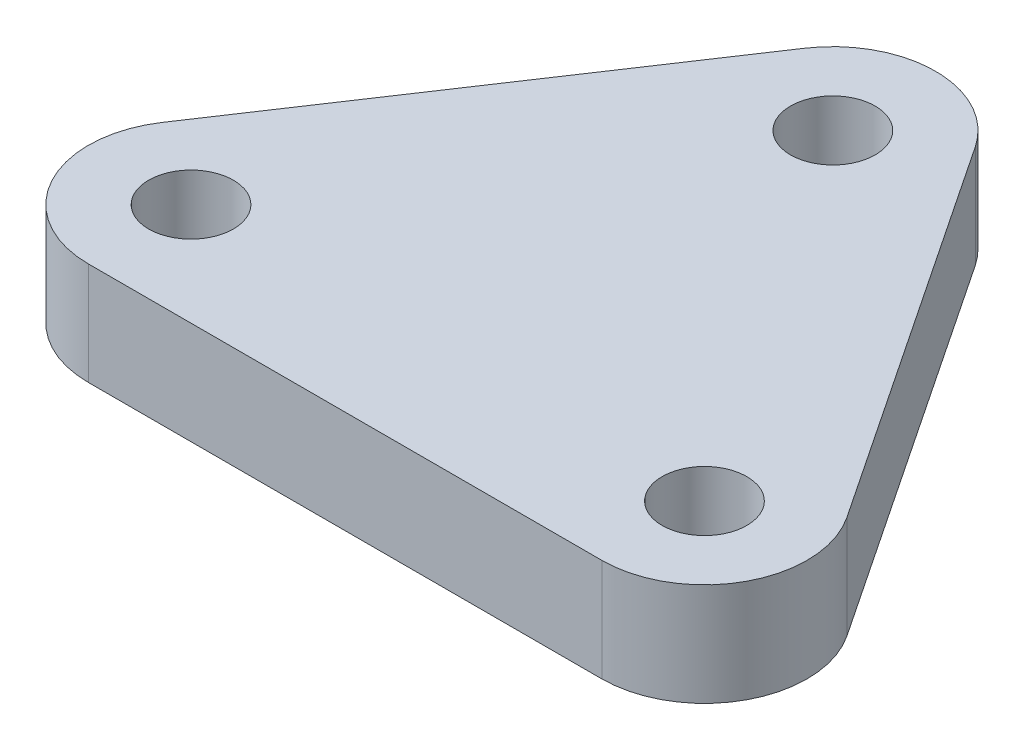
from build123d import *

# Parameters (mm, degrees)
EXTRUDE_1_DEPTH    = 4
HOLE_WIZARD_M4_1_D = 3.3


with BuildPart() as part:
    # 草图1 → 凸台-拉伸1 (new body)
    with BuildSketch(Plane(origin=(0, 0, 0), x_dir=(1, 0, 0), z_dir=(0, 1, 0))):
        with BuildLine():
            Line((-3.328201177, 17.218800785), (-13.328201177, 2.218800785))
            ThreePointArc((-13.328201177, 2.218800785), (-13.526698395, -1.887431702), (-10, -4))
            Line((-10, -4), (10, -4))
            ThreePointArc((10, -4), (13.526698395, -1.887431702), (13.328201177, 2.218800785))
            Line((13.328201177, 2.218800785), (3.328201177, 17.218800785))
            ThreePointArc((3.328201177, 17.218800785), (0, 19), (-3.328201177, 17.218800785))
        make_face()
    extrude(amount=EXTRUDE_1_DEPTH)

    # M4 螺纹孔1 (through all)
    with Locations(Plane(origin=(0, 4, 0), x_dir=(1, 0, 0), z_dir=(0, 1, 0))):
        with Locations((0, 15), (-10, 0), (10, 0)):
            Hole(HOLE_WIZARD_M4_1_D / 2)


solid = part.part
